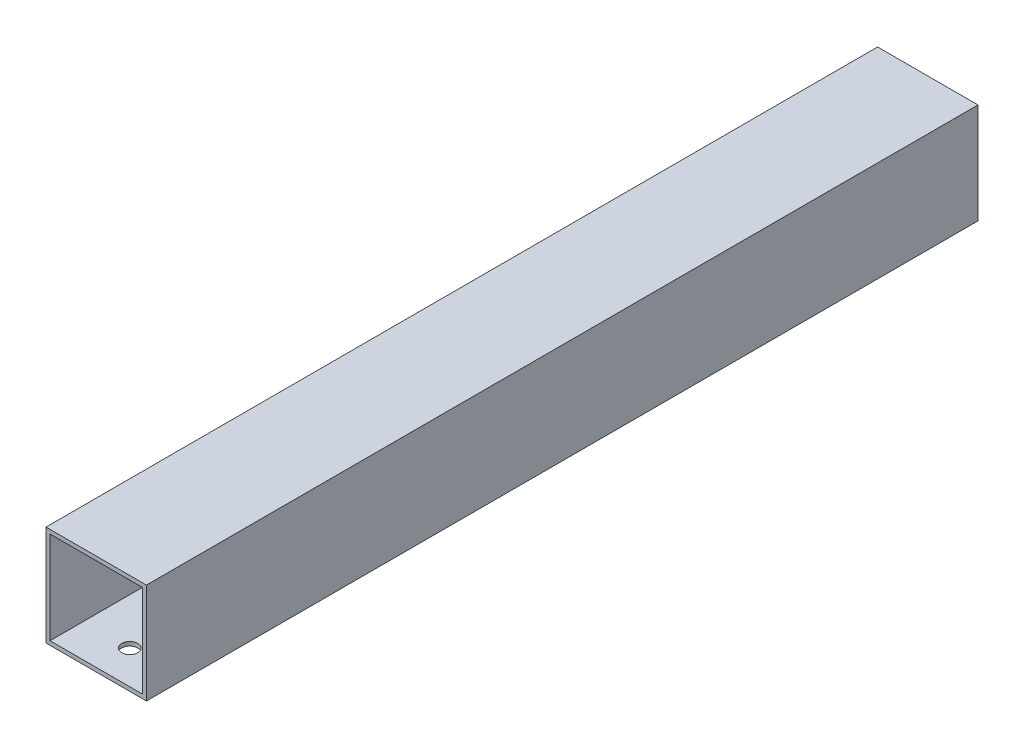
from build123d import *

# Parameters (mm, degrees)
SKETCH1_W          = 50
SKETCH1_H          = 50
SKETCH1_W_2        = 46
SKETCH1_H_2        = 46
STEELTUBE_DEPTH    = 414
SKETCH2_R          = 4
CUT_EXTRUDE1_DEPTH = 2


with BuildPart() as part:
    # Sketch1 → steelTube (new body)
    with BuildSketch(Plane.XY):
        with Locations((-23, 23)):
            Rectangle(SKETCH1_W, SKETCH1_H)
        with Locations((-23, 23)):
            Rectangle(SKETCH1_W_2, SKETCH1_H_2, mode=Mode.SUBTRACT)
    extrude(amount=STEELTUBE_DEPTH)

    # Sketch2 → Cut-Extrude1 (cut)
    with BuildSketch(Plane.XZ.offset(2)):
        with Locations((-23, 50.3)):
            Circle(SKETCH2_R)
        with Locations((-23, 397.3)):
            Circle(SKETCH2_R)
    extrude(amount=-CUT_EXTRUDE1_DEPTH, mode=Mode.SUBTRACT)


solid = part.part
